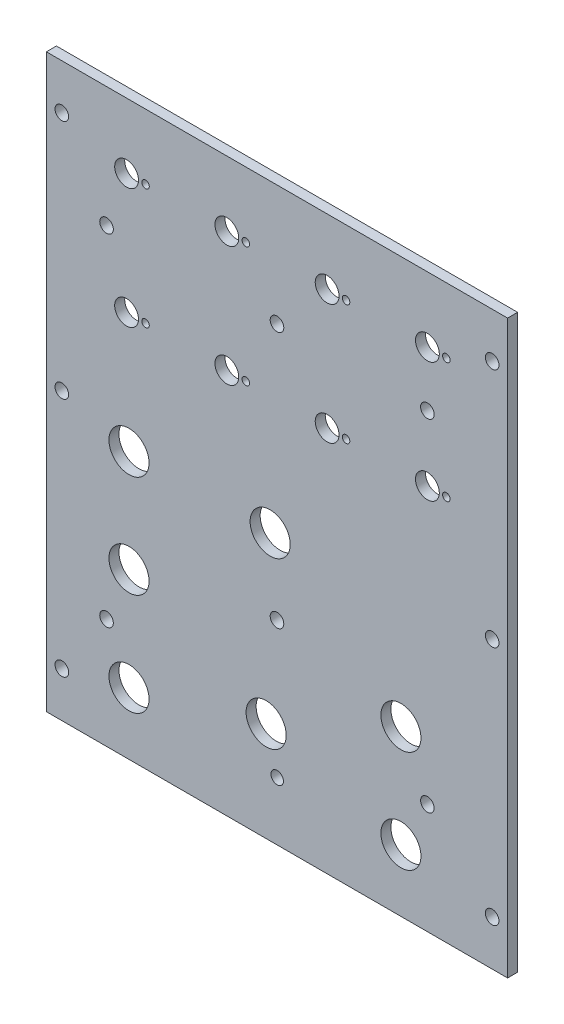
from build123d import *

# Parameters (mm, degrees)
SKETCH1_W                        = 146.05
SKETCH1_H                        = 180.975
BOSS_EXTRUDE1_DEPTH              = 3.175
F_6_CLEARANCE_HOLE1_D            = 4.3053
F_19_64_0_29688_DIAMETER_HOLE1_D = 7.540752
F_1_2_0_5_DIAMETER_HOLE1_D       = 12.7
F_5_32_0_15625_DIAMETER_HOLE1_D  = 3.96875
F_3_32_0_09375_DIAMETER_HOLE1_D  = 2.38125


with BuildPart() as part:
    # Sketch1 → Boss-Extrude1 (new body)
    with BuildSketch(Plane.XY):
        with Locations((-73.025, 90.4875)):
            Rectangle(SKETCH1_W, SKETCH1_H)
    extrude(amount=-BOSS_EXTRUDE1_DEPTH)

    # #6 Clearance Hole1 (through all)
    with Locations(Plane(origin=(0, 0, -3.175), x_dir=(-1, 0, 0), z_dir=(0, 0, -1))):
        with Locations((25.4, 142.875), (73.025, 142.875), (127, 142.875), (25.4, 34.925), (73.025, 61.647038728), (127, 34.925), (4.8895, 14.2875), (141.1605, 14.2875), (4.8895, 90.4875), (141.1605, 90.4875), (141.1605, 166.6875), (4.8895, 166.6875)):
            Hole(F_6_CLEARANCE_HOLE1_D / 2)

    # 19/64 (0.29688) Diameter Hole1 (through all)
    with Locations(Plane(origin=(0, 0, -3.175), x_dir=(-1, 0, 0), z_dir=(0, 0, -1))):
        with Locations((25.4, 160.3248), (57.15, 160.3248), (88.9, 160.3248), (120.65, 160.3248), (25.4, 122.2248), (57.15, 122.2248), (88.9, 122.2248), (120.65, 122.2248)):
            Hole(F_19_64_0_29688_DIAMETER_HOLE1_D / 2)

    # 1/2 (0.5) Diameter Hole1 (through all)
    with Locations(Plane(origin=(0, 0, -3.175), x_dir=(-1, 0, 0), z_dir=(0, 0, -1))):
        with Locations((75.184, 84.455), (119.888, 84.455), (119.888, 52.07), (33.782, 52.07), (33.782, 19.685), (119.888, 19.685), (76.454, 31.496)):
            Hole(F_1_2_0_5_DIAMETER_HOLE1_D / 2)

    # 5/32 (0.15625) Diameter Hole1 (through all)
    with Locations(Plane(origin=(0, 0, -3.175), x_dir=(-1, 0, 0), z_dir=(0, 0, -1))):
        with Locations((72.963204011, 18.468172011)):
            Hole(F_5_32_0_15625_DIAMETER_HOLE1_D / 2)

    # 3/32 (0.09375) Diameter Hole1 (through all)
    with Locations(Plane(origin=(0, 0, -3.175), x_dir=(-1, 0, 0), z_dir=(0, 0, -1))):
        with Locations((19.4, 160.324800026), (51.15, 160.324800026), (82.9, 160.324800026), (114.65, 160.324800026), (114.65, 122.224800026), (82.9, 122.224800026), (51.15, 122.224800026), (19.4, 122.224800026)):
            Hole(F_3_32_0_09375_DIAMETER_HOLE1_D / 2)


solid = part.part
